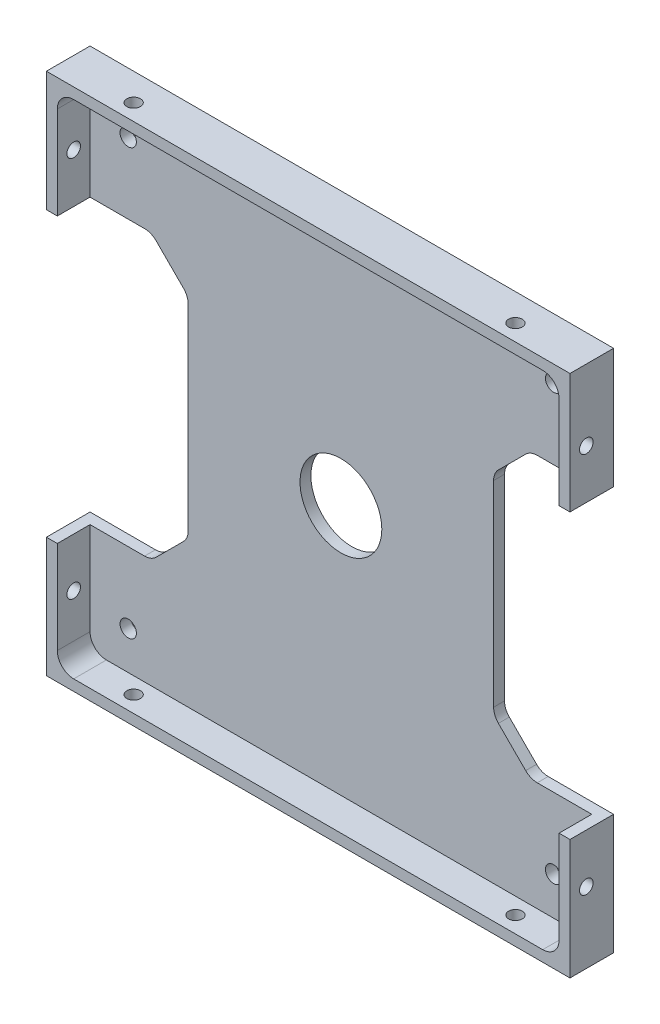
from build123d import *

# Parameters (mm, degrees)
SKETCH1_W                       = 96
SKETCH1_H                       = 96
BOSS_EXTRUDE1_DEPTH             = 8
SKETCH2_W                       = 92
SKETCH2_H                       = 92
COMPONENT_PLATFORM_DEPTH        = 6
CABLE_SLOTS_DEPTH               = 6
SKETCH4_R                       = 7.5
CENTER_MASS_CUT_DEPTH           = 6
INNER_CORNER_FILLETS_R          = 3
TAP_DRILL_FOR_M3X0_5_TAP1_D     = 2.5
TAP_DRILL_FOR_M3X0_5_TAP1_DEPTH = 2
TAP_DRILL_FOR_M3X0_5_TAP2_D     = 2.5
TAP_DRILL_FOR_M3X0_5_TAP2_DEPTH = 2
F_3_0MM_DOWEL_HOLE3_D           = 3
F_3_0MM_DOWEL_HOLE3_DEPTH       = 10
F_3_0MM_DOWEL_HOLE3_TIP         = 0.901290929


with BuildPart() as part:
    # Sketch1 → Boss-Extrude1 (new body)
    with BuildSketch(Plane.XY):
        Rectangle(SKETCH1_W, SKETCH1_H)
    extrude(amount=BOSS_EXTRUDE1_DEPTH)

    # Sketch2 → Component Platform (cut)
    with BuildSketch(Plane.XY.offset(8)):
        Rectangle(SKETCH2_W, SKETCH2_H)
    extrude(amount=-COMPONENT_PLATFORM_DEPTH, mode=Mode.SUBTRACT)

    # Sketch3 → Cable Slots (cut, symmetric)
    with BuildSketch(Plane.XY.offset(2)):
        with BuildLine():
            Line((-33.878679656, -25.121320344), (-28.878679656, -20.121320344))
            ThreePointArc((-28.878679656, -20.121320344), (-28.228361402, -19.148050297), (-28, -18))
            Line((-28, -18), (-28, 18))
            ThreePointArc((-28, 18), (-28.228361402, 19.148050297), (-28.878679656, 20.121320344))
            Line((-28.878679656, 20.121320344), (-33.878679656, 25.121320344))
            ThreePointArc((-33.878679656, 25.121320344), (-34.851949703, 25.771638598), (-36, 26))
            Line((-36, 26), (-48, 26))
            Line((-48, 26), (-48, -26))
            Line((-48, -26), (-36, -26))
            ThreePointArc((-36, -26), (-34.851949703, -25.771638598), (-33.878679656, -25.121320344))
        make_face()
        with BuildLine():
            Line((48, -26), (48, 26))
            Line((48, 26), (36, 26))
            ThreePointArc((36, 26), (34.851949703, 25.771638598), (33.878679656, 25.121320344))
            Line((33.878679656, 25.121320344), (28.878679656, 20.121320344))
            ThreePointArc((28.878679656, 20.121320344), (28.228361402, 19.148050297), (28, 18))
            Line((28, 18), (28, -18))
            ThreePointArc((28, -18), (28.228361402, -19.148050297), (28.878679656, -20.121320344))
            Line((28.878679656, -20.121320344), (33.878679656, -25.121320344))
            ThreePointArc((33.878679656, -25.121320344), (34.851949703, -25.771638598), (36, -26))
            Line((36, -26), (48, -26))
        make_face()
    extrude(amount=CABLE_SLOTS_DEPTH, both=True, mode=Mode.SUBTRACT)

    # Sketch4 → Center Mass Cut (cut)
    with BuildSketch(Plane.XY.offset(2)):
        Circle(SKETCH4_R)
    extrude(amount=-CENTER_MASS_CUT_DEPTH, mode=Mode.SUBTRACT)

    # Inner Corner Fillets
    inner_corner_fillets_edges = [part.edges().sort_by_distance(p)[0] for p in [
        (-46, -46, 5),
        (-46, 46, 5),
        (46, 46, 5),
        (46, -46, 5),
    ]]
    fillet(inner_corner_fillets_edges, radius=INNER_CORNER_FILLETS_R)

    # Tap Drill for M3x0.5 Tap1
    with Locations(Plane(origin=(0, -48, 0), x_dir=(-1, 0, 0), z_dir=(0, -1, 0))):
        with Locations((35, -5), (-35, -5)):
            tap_drill_for_m3x0_5_tap1 = Hole(TAP_DRILL_FOR_M3X0_5_TAP1_D / 2, depth=TAP_DRILL_FOR_M3X0_5_TAP1_DEPTH)

    # Tap Drill for M3x0.5 Tap2
    with Locations(Plane(origin=(48, 0, 0), x_dir=(0, 0, -1), z_dir=(1, 0, 0))):
        with Locations((-5, -35), (-5, 35)):
            tap_drill_for_m3x0_5_tap2 = Hole(TAP_DRILL_FOR_M3X0_5_TAP2_D / 2, depth=TAP_DRILL_FOR_M3X0_5_TAP2_DEPTH)

    # Mirror1: Tap Drill for M3x0.5 Tap1 across plane
    add(tap_drill_for_m3x0_5_tap1.mirror(Plane(origin=(0, 0, 0), x_dir=(0, 0, 1), z_dir=(0, -1, 0))), mode=Mode.SUBTRACT)

    # Mirror2: Tap Drill for M3x0.5 Tap2 across plane
    add(tap_drill_for_m3x0_5_tap2.mirror(Plane(origin=(0, 0, 0), x_dir=(0, 0, 1), z_dir=(1, 0, 0))), mode=Mode.SUBTRACT)

    # Ø3.0mm Dowel Hole3
    with Locations(Plane.XY.offset(2)):
        with Locations((-39, -39), (39, -39), (39, 39), (-39, 39)):
            Hole(F_3_0MM_DOWEL_HOLE3_D / 2, depth=F_3_0MM_DOWEL_HOLE3_DEPTH)
            with Locations((0, 0, -(F_3_0MM_DOWEL_HOLE3_DEPTH + F_3_0MM_DOWEL_HOLE3_TIP / 2))):  # 118° drill point
                Cone(0, F_3_0MM_DOWEL_HOLE3_D / 2, F_3_0MM_DOWEL_HOLE3_TIP, mode=Mode.SUBTRACT)


solid = part.part
